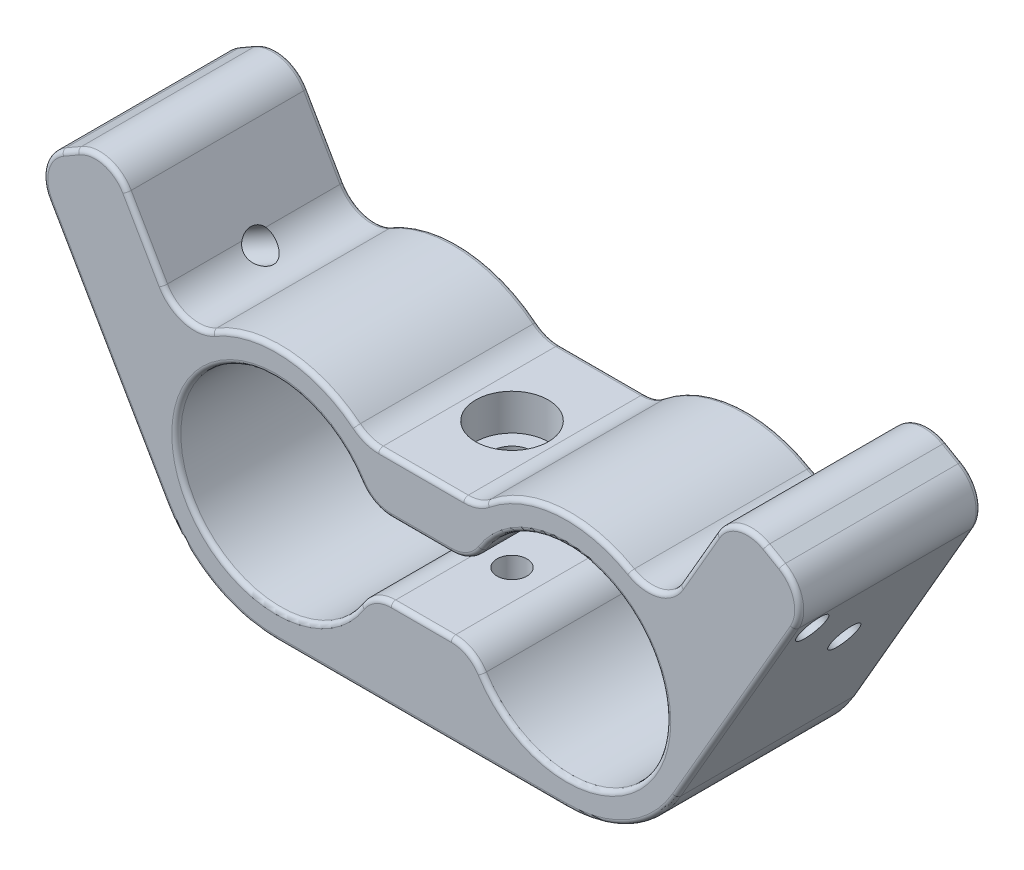
from build123d import *

# Parameters (mm, degrees)
EXTRUDE_2_DEPTH             = 20
HOLE_WIZARD_M41_D           = 4.5
HOLE_WIZARD_M41_DEPTH       = 6
HOLE_WIZARD_M41_CBORE_D     = 8
HOLE_WIZARD_M41_CBORE_DEPTH = 4
M4X0_71_D                   = 3.3
FILLET_1_R                  = 4
FILLET_2_R                  = 0.5
M4X0_72_D                   = 3.3


with BuildPart() as part:
    # Эскиз1 → Бобышка-Вытянуть2 (new body)
    with BuildSketch(Plane.XY):
        with BuildLine():
            Line((-6.202041029, 10), (6.202041029, 10))
            ThreePointArc((6.202041029, 10), (16.267083523, 13.997452139), (26.172305548, 9.618950039))
            Line((26.172305548, 9.618950039), (34.464101615, 23.980762114))
            Line((34.464101615, 23.980762114), (43.124355653, 18.980762114))
            Line((43.124355653, 18.980762114), (28.124355653, -7))
            ThreePointArc((28.124355653, -7), (23, -12.124355653), (16, -14))
            Line((16, -14), (-16, -14))
            ThreePointArc((-16, -14), (-23, -12.124355653), (-28.124355653, -7))
            Line((-28.124355653, -7), (-43.124355653, 18.980762114))
            Line((-43.124355653, 18.980762114), (-34.464101615, 23.980762114))
            Line((-34.464101615, 23.980762114), (-26.172305548, 9.618950039))
            ThreePointArc((-26.172305548, 9.618950039), (-16.267083523, 13.997452139), (-6.202041029, 10))
        make_face()
        with BuildLine():
            Line((-5.753049234, 4), (5.753049234, 4))
            ThreePointArc((5.753049234, 4), (27, 0), (5.753049234, -4))
            Line((5.753049234, -4), (-5.753049234, -4))
            ThreePointArc((-5.753049234, -4), (-27, 0), (-5.753049234, 4))
        make_face(mode=Mode.SUBTRACT)
    extrude(amount=EXTRUDE_2_DEPTH)

    # Цековка для винта с внутренним шестигранником M41
    with Locations(Plane(origin=(0, 10, 0), x_dir=(1, 0, 0), z_dir=(0, 1, 0))):
        with Locations((0, -10)):
            CounterBoreHole(HOLE_WIZARD_M41_D / 2, HOLE_WIZARD_M41_CBORE_D / 2, HOLE_WIZARD_M41_CBORE_DEPTH, depth=HOLE_WIZARD_M41_DEPTH)

    # Отверстие обработанное метчиком M4x0.71 (through all)
    with Locations(Plane(origin=(0, -4, 0), x_dir=(1, 0, 0), z_dir=(0, 1, 0))):
        with Locations((0, -10)):
            Hole(M4X0_71_D / 2)

    # Скругление1
    fillet_1_edges = [part.edges().sort_by_distance(p)[0] for p in [
        (-6.202041029, 10, 10),
        (6.202041029, 10, 10),
        (26.172305548, 9.618950039, 10),
        (34.464101615, 23.980762114, 10),
        (43.124355653, 18.980762114, 10),
        (-43.124355653, 18.980762114, 10),
        (-34.464101615, 23.980762114, 10),
        (-26.172305548, 9.618950039, 10),
        (-5.753049234, 4, 10),
        (-5.753049234, -4, 10),
        (5.753049234, -4, 10),
        (5.753049234, 4, 10),
    ]]
    fillet(fillet_1_edges, radius=FILLET_1_R)

    # Скругление2
    fillet_2_edges = [part.edges().sort_by_distance(p)[0] for p in [
        (34.624355653, 4.258330249, 0),
        (23, -12.124355653, 0),
        (0, -14, 0),
        (-23, -12.124355653, 0),
        (-23, -12.124355653, 20),
        (0, -14, 20),
        (23, -12.124355653, 20),
        (34.624355653, 4.258330249, 20),
        (-27, 0, 0),
        (-27, 0, 20),
        (-14.908583246, 13.957392646, 0),
        (0, 10, 0),
        (14.908583246, 13.957392646, 0),
        (30.464101615, 17.052558883, 0),
        (38.794228634, 21.480762114, 0),
        (-34.624355653, 4.258330249, 0),
        (-38.794228634, 21.480762114, 0),
        (-30.464101615, 17.052558883, 0),
        (0, -4, 0),
        (27, 0, 0),
        (0, 4, 0),
        (34.89292705, 22.380363804, 0),
        (41.523957343, 18.551936679, 0),
        (-34.89292705, 22.380363804, 0),
        (-41.523957343, 18.551936679, 0),
        (-5.243606026, 4.497619857, 0),
        (5.243606026, 4.497619857, 0),
        (5.243606026, -4.497619857, 0),
        (-5.243606026, -4.497619857, 0),
        (0, -4, 20),
        (-14.908583246, 13.957392646, 20),
        (-30.464101615, 17.052558883, 20),
        (-38.794228634, 21.480762114, 20),
        (-34.624355653, 4.258330249, 20),
        (38.794228634, 21.480762114, 20),
        (30.464101615, 17.052558883, 20),
        (14.908583246, 13.957392646, 20),
        (0, 10, 20),
        (0, 4, 20),
        (27, 0, 20),
        (34.89292705, 22.380363804, 20),
        (41.523957343, 18.551936679, 20),
        (-34.89292705, 22.380363804, 20),
        (-41.523957343, 18.551936679, 20),
        (-5.243606026, 4.497619857, 20),
        (5.243606026, 4.497619857, 20),
        (5.243606026, -4.497619857, 20),
        (-5.243606026, -4.497619857, 20),
        (26.03527618, 11.724753963, 0),
        (26.03527618, 11.724753963, 20),
        (6.019624834, 10.228763834, 0),
        (6.019624834, 10.228763834, 20),
        (-6.019624834, 10.228763834, 0),
        (-6.019624834, 10.228763834, 20),
        (-26.03527618, 11.724753963, 0),
        (-26.03527618, 11.724753963, 20),
    ]]
    fillet(fillet_2_edges, radius=FILLET_2_R)

    # Отверстие обработанное метчиком M4x0.72 (through all)
    with Locations(Plane(origin=(24.124355653, -13.92820323, 0), x_dir=(-0.5, -0.866025404, 0), z_dir=(0.866025404, -0.5, 0))):
        with Locations((-25, -10)):
            m4x0_72 = Hole(M4X0_72_D / 2)

    # Зеркальное отражение1: Отверстие обработанное метчиком M4x0.72 across plane
    add(m4x0_72.mirror(Plane(origin=(0, 0, 0), x_dir=(0, 0, 1), z_dir=(1, 0, 0))), mode=Mode.SUBTRACT)

    # Эскиз13 → Отверстие обработанное метчиком M4x0.73 (revolve, cut)
    with BuildSketch(Plane(origin=(-40.159889559, 13.846156221, 17.071067812), x_dir=(0.5, -0.866025404, 0), z_dir=(0, 0, 1))):
        Polygon((0, 0), (0, 4.991420021), (1.65, 4), (1.65, 0), align=None)
    m4x0_73 = revolve(axis=Axis((-45.659150873, 10.671156221, 17.071067812), (0.866025404, 0.5, 0)), mode=Mode.SUBTRACT)

    # Зеркальное отражение3: Отверстие обработанное метчиком M4x0.73 across plane
    add(m4x0_73.mirror(Plane(origin=(0, 0, 0), x_dir=(0, 0, 1), z_dir=(1, 0, 0))), mode=Mode.SUBTRACT)


solid = part.part
